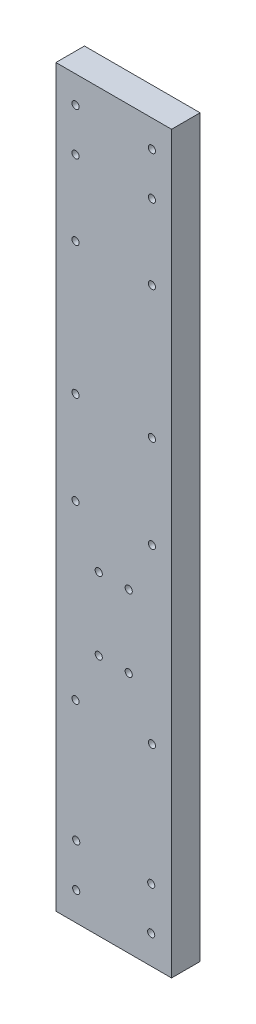
from build123d import *

# Parameters (mm, degrees)
SKETCH1_W           = 16.2
SKETCH1_H           = 102.96
SKETCH1_R           = 0.5
BOSS_EXTRUDE1_DEPTH = 4


with BuildPart() as part:
    # Sketch1 → Boss-Extrude1 (new body)
    with BuildSketch(Plane.XY):
        with Locations((8.1, 51.48)):
            Rectangle(SKETCH1_W, SKETCH1_H)
        with Locations((13.45, 51.14)):
            Circle(SKETCH1_R, mode=Mode.SUBTRACT)
        with Locations((13.45, 93.165)):
            Circle(SKETCH1_R, mode=Mode.SUBTRACT)
        with Locations((2.75, 99.165)):
            Circle(SKETCH1_R, mode=Mode.SUBTRACT)
        with Locations((2.75, 51.14)):
            Circle(SKETCH1_R, mode=Mode.SUBTRACT)
        with Locations((6, 44.14)):
            Circle(SKETCH1_R, mode=Mode.SUBTRACT)
        with Locations((13.45, 27)):
            Circle(SKETCH1_R, mode=Mode.SUBTRACT)
        with Locations((6, 34)):
            Circle(SKETCH1_R, mode=Mode.SUBTRACT)
        with Locations((2.75, 27)):
            Circle(SKETCH1_R, mode=Mode.SUBTRACT)
        with Locations((2.75, 93.165)):
            Circle(SKETCH1_R, mode=Mode.SUBTRACT)
        with Locations((13.45, 82.665)):
            Circle(SKETCH1_R, mode=Mode.SUBTRACT)
        with Locations((13.45, 64.14)):
            Circle(SKETCH1_R, mode=Mode.SUBTRACT)
        with Locations((13.45, 99.165)):
            Circle(SKETCH1_R, mode=Mode.SUBTRACT)
        with Locations((10.2, 44.14)):
            Circle(SKETCH1_R, mode=Mode.SUBTRACT)
        with Locations((2.75, 82.665)):
            Circle(SKETCH1_R, mode=Mode.SUBTRACT)
        with Locations((2.85, 10)):
            Circle(SKETCH1_R, mode=Mode.SUBTRACT)
        with Locations((13.35, 10)):
            Circle(SKETCH1_R, mode=Mode.SUBTRACT)
        with Locations((13.35, 4)):
            Circle(SKETCH1_R, mode=Mode.SUBTRACT)
        with Locations((2.85, 4)):
            Circle(SKETCH1_R, mode=Mode.SUBTRACT)
        with Locations((2.75, 64.14)):
            Circle(SKETCH1_R, mode=Mode.SUBTRACT)
        with Locations((10.2, 34)):
            Circle(SKETCH1_R, mode=Mode.SUBTRACT)
    extrude(amount=BOSS_EXTRUDE1_DEPTH)


solid = part.part
